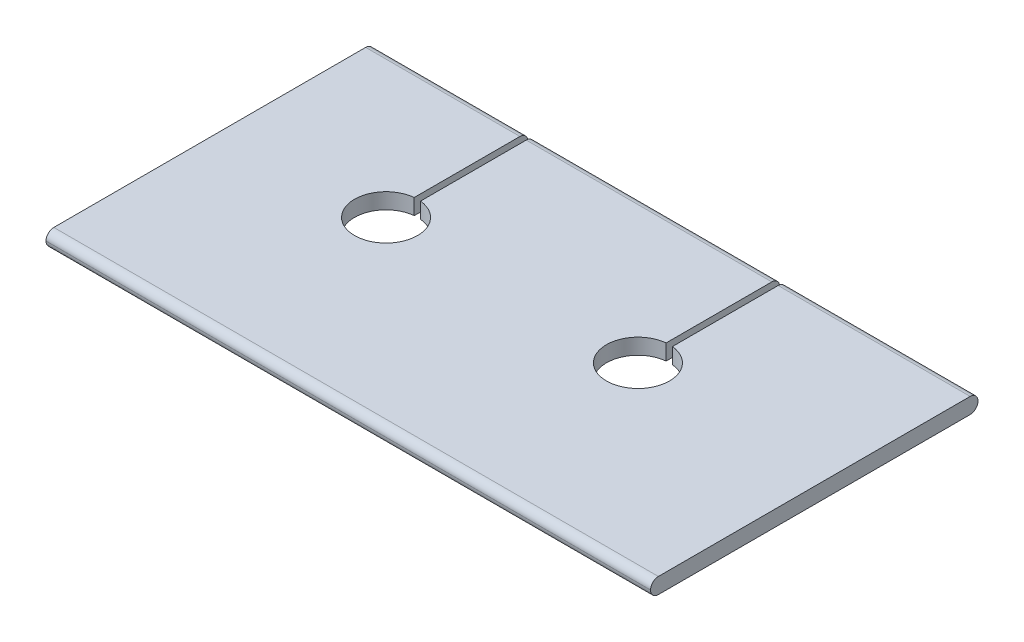
from build123d import *

# Parameters (mm, degrees)
BOSS_EXTRUDE1_DEPTH = 48
SKETCH2_W           = 0.5
SKETCH2_H           = 4.044844813
CUT_EXTRUDE1_DEPTH  = 2.25


with BuildPart() as part:
    # Sketch1 → Boss-Extrude1 (new body)
    with BuildSketch(Plane(origin=(0, 0, 0), x_dir=(0, 0, -1), z_dir=(1, 0, 0))):
        with BuildLine():
            Line((12.38, 0.625), (-12.38, 0.625))
            ThreePointArc((-12.38, 0.625), (-12.818406204, 0.443406204), (-13, 0.005))
            Line((-13, 0.005), (-13, -0.005))
            ThreePointArc((-13, -0.005), (-12.818406204, -0.443406204), (-12.38, -0.625))
            Line((-12.38, -0.625), (12.38, -0.625))
            ThreePointArc((12.38, -0.625), (12.818406204, -0.443406204), (13, -0.005))
            Line((13, -0.005), (13, 0.005))
            ThreePointArc((13, 0.005), (12.818406204, 0.443406204), (12.38, 0.625))
        make_face()
    extrude(amount=BOSS_EXTRUDE1_DEPTH)

    # Sketch2 → Cut-Extrude1 (cut, through all)
    with BuildSketch(Plane(origin=(0, 0.625, 0), x_dir=(1, 0, 0), z_dir=(0, 1, 0))):
        with BuildLine():
            ThreePointArc((12.25, 3.987468593), (12.5, -1), (12.75, 3.987468593))
            Line((12.75, 3.987468593), (12.75, 12.38))
            Line((12.75, 12.38), (12.25, 12.38))
            Line((12.25, 12.38), (12.25, 3.987468593))
        make_face()
        with BuildLine():
            Line((32.75, 12.38), (32.25, 12.38))
            Line((32.25, 12.38), (32.25, 3.987468593))
            ThreePointArc((32.25, 3.987468593), (32.5, -1), (32.75, 3.987468593))
            Line((32.75, 3.987468593), (32.75, 12.38))
        make_face()
        with Locations((12.5, 14.402422407)):
            Rectangle(SKETCH2_W, SKETCH2_H)
        with Locations((32.5, 14.402422407)):
            Rectangle(SKETCH2_W, SKETCH2_H)
    extrude(amount=-CUT_EXTRUDE1_DEPTH, mode=Mode.SUBTRACT)


solid = part.part
